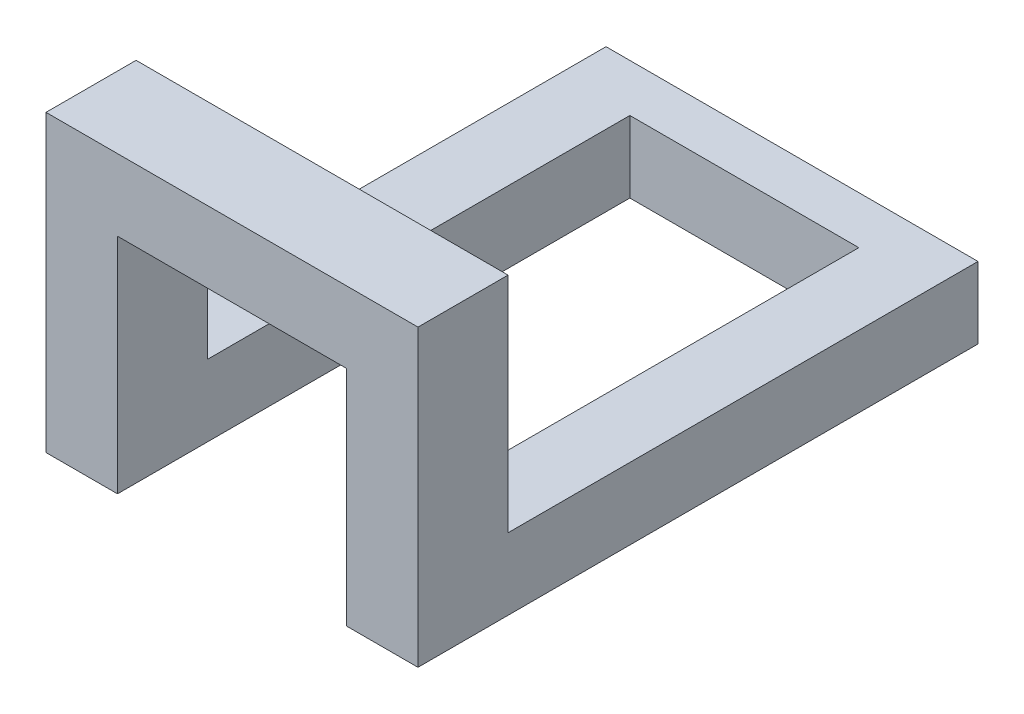
from build123d import *

# Parameters (mm, degrees)
SKETCH1_W           = 19.82
SKETCH1_H           = 4.8
BOSS_EXTRUDE1_DEPTH = 3.81
SKETCH2_W           = 3.81
SKETCH2_H           = 4.8
BOSS_EXTRUDE2_DEPTH = 11.89
SKETCH3_W           = 3.81
SKETCH3_H           = 3.81
BOSS_EXTRUDE3_DEPTH = 22.5
SKETCH4_W           = 19.82
SKETCH4_H           = 3.81
BOSS_EXTRUDE4_DEPTH = 2.54


with BuildPart() as part:
    # Sketch1 → Boss-Extrude1 (new body)
    with BuildSketch(Plane(origin=(0, 0, 0), x_dir=(1, 0, 0), z_dir=(0, 1, 0))):
        with Locations((34.380252927, 12.547082461)):
            Rectangle(SKETCH1_W, SKETCH1_H)
    extrude(amount=BOSS_EXTRUDE1_DEPTH)

    # Sketch2 → Boss-Extrude2 (add)
    with BuildSketch(Plane.XZ):
        with Locations((26.375252927, -12.547082461)):
            Rectangle(SKETCH2_W, SKETCH2_H)
        with Locations((42.385252927, -12.547082461)):
            Rectangle(SKETCH2_W, SKETCH2_H)
    extrude(amount=BOSS_EXTRUDE2_DEPTH)

    # Sketch3 → Boss-Extrude3 (add)
    with BuildSketch(Plane(origin=(0, 0, -14.947082461), x_dir=(-1, 0, 0), z_dir=(0, 0, -1))):
        with Locations((-42.385252927, -9.985)):
            Rectangle(SKETCH3_W, SKETCH3_H)
        with Locations((-26.375252927, -9.985)):
            Rectangle(SKETCH3_W, SKETCH3_H)
    extrude(amount=BOSS_EXTRUDE3_DEPTH)

    # Sketch4 → Boss-Extrude4 (add)
    with BuildSketch(Plane(origin=(0, 0, -37.447082461), x_dir=(-1, 0, 0), z_dir=(0, 0, -1))):
        with Locations((-34.380252927, -9.985)):
            Rectangle(SKETCH4_W, SKETCH4_H)
    extrude(amount=BOSS_EXTRUDE4_DEPTH)


solid = part.part
